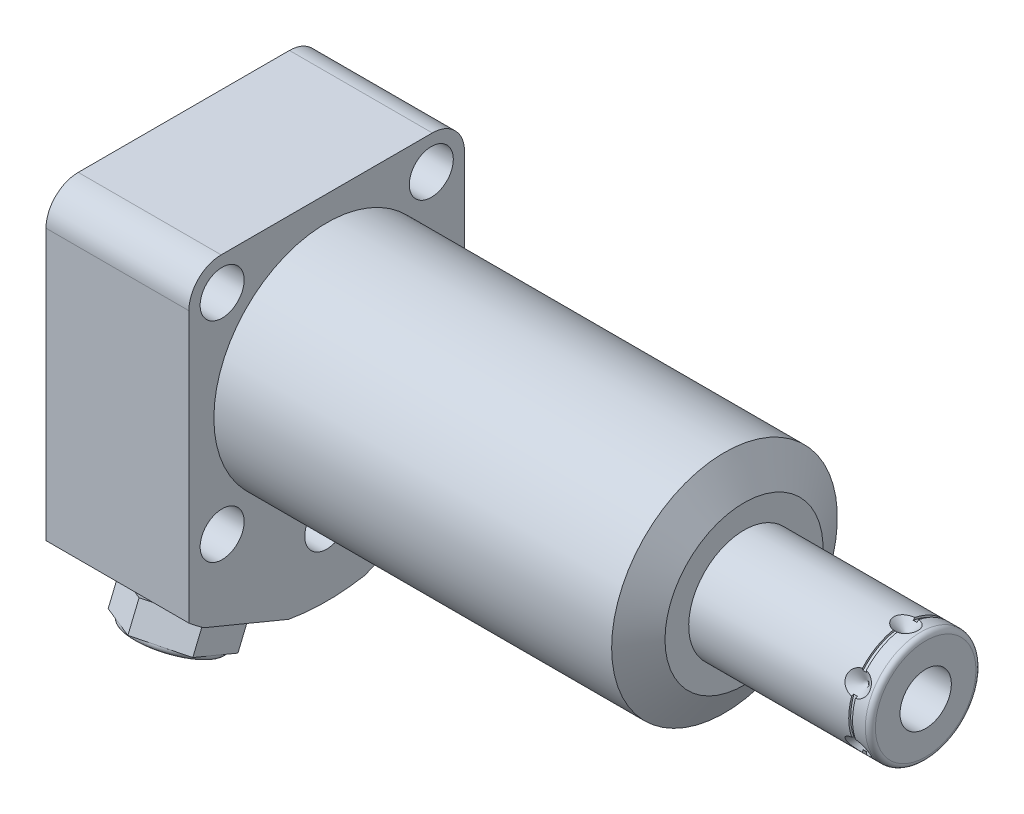
from build123d import *

# Parameters (mm, degrees)
EXTRUDE1_DEPTH           = 83.82
EXTRUDE1_DEPTH_BACK      = 28.702
CUT_EXTRUDE1_REACH       = 100.269
SKETCH2_R                = 22.6695
SKETCH11_W               = 0.762
SKETCH11_H               = 0.381
EXTRUDE2_DEPTH           = 7.87
SKETCH15_R               = 2.7432
EXTRUDE3_DEPTH           = 2.9972
CUT_EXTRUDE2_DEPTH       = 2.54
CHAMFER1_SIZE            = 0.381
CHAMFER1_OF_MIRROR2_SIZE = 0.381
SKETCH21_R               = 0.889
FILLET1_R                = 6.477
SKETCH22_W               = 4.4196
SKETCH22_H               = 28.702
HOLE1_AT_2_COUNT         = 2
HOLE1_AT_2_PITCH         = 54.877785999
HOLE1_AT_3_COUNT         = 2
HOLE1_AT_3_PITCH         = 54.877785999
HOLE1_AT_4_COUNT         = 2
HOLE1_AT_4_PITCH         = 22.73112685
HOLE1_AT_5_COUNT         = 2
HOLE1_AT_5_PITCH         = 22.73112685
CIRPATTERN1_COUNT        = 6


with BuildPart() as part:
    # Sketch1 → Extrude1 (new, two sides)
    with BuildSketch(Plane(origin=(0, 0, 0), x_dir=(0, 0, -1), z_dir=(1, 0, 0))) as extrude1_sk:
        with BuildLine():
            Line((-27.686, 27.686), (-27.686, -33.136049915))
            ThreePointArc((-27.686, -33.136049915), (-26.189365587, -34.331174319), (-24.641206283, -35.458755659))
            Line((-24.641206283, -35.458755659), (-7.649162519, -42.497090639))
            ThreePointArc((-7.649162519, -42.497090639), (0, -43.18), (7.649162519, -42.497090639))
            Line((7.649162519, -42.497090639), (24.641206283, -35.458755659))
            ThreePointArc((24.641206283, -35.458755659), (26.189365587, -34.331174319), (27.686, -33.136049915))
            Line((27.686, -33.136049915), (27.686, 27.686))
            Line((27.686, 27.686), (-27.686, 27.686))
        make_face()
    extrude(amount=EXTRUDE1_DEPTH)
    extrude(extrude1_sk.sketch, amount=-EXTRUDE1_DEPTH_BACK)

    # Sketch2 → Cut-Extrude1 (cut, up to next)
    with BuildSketch(Plane(origin=(0, 0, 0), x_dir=(0, 0, -1), z_dir=(1, 0, 0)), mode=Mode.PRIVATE) as cut_extrude1_sk1:
        with BuildLine():
            Line((27.686, 27.686), (-27.686, 27.686))
            Line((-27.686, 27.686), (-27.686, -33.136049915))
            ThreePointArc((-27.686, -33.136049915), (-26.189365587, -34.331174319), (-24.641206283, -35.458755659))
            Line((-24.641206283, -35.458755659), (-7.649162519, -42.497090639))
            ThreePointArc((-7.649162519, -42.497090639), (0, -43.18), (7.649162519, -42.497090639))
            Line((7.649162519, -42.497090639), (24.641206283, -35.458755659))
            ThreePointArc((24.641206283, -35.458755659), (26.189365587, -34.331174319), (27.686, -33.136049915))
            Line((27.686, -33.136049915), (27.686, 27.686))
        make_face()
        Circle(SKETCH2_R, mode=Mode.SUBTRACT)
    cut_extrude1_tool1 = extrude(cut_extrude1_sk1.sketch, amount=CUT_EXTRUDE1_REACH, mode=Mode.PRIVATE) & part.part
    add(cut_extrude1_tool1.solids().sort_by_distance((0, -33.616138, -25.643904))[0], mode=Mode.SUBTRACT)

    # Sketch3 → Cut-Revolve1 (revolve, cut)
    with BuildSketch(Plane.XY, mode=Mode.PRIVATE) as cut_revolve1_sk:
        Polygon((79.897193596, 22.6695), (83.82, 15.875), (83.82, 22.6695), align=None)
    revolve(cut_revolve1_sk.sketch.rotate(Axis((23.304450239, 0, 0), (1, 0, 0)), 90), axis=Axis((23.304450239, 0, 0), (1, 0, 0)), mode=Mode.SUBTRACT)

    # S2D0002 → Cut-Revolve2 (revolve, cut)
    with BuildSketch(Plane(origin=(-24.9936, -18.1864, 11.8618), x_dir=(0, 1, 0), z_dir=(0, 0, 1)), mode=Mode.PRIVATE) as cut_revolve2_sk:
        Polygon((-7.1374, 2.2606), (-4.6863, 2.2606), (-4.6863, 3.7084), (-10.3886, 3.7084), (-10.3886, -9.7282), (-9.144, -9.7282), (-9.144, -0.7366), (-7.1374, -0.7366), align=None)
    cut_revolve2 = revolve(cut_revolve2_sk.sketch.rotate(Axis((-1.435104963, -28.575, 11.8618), (-1, 0, 0)), 90), axis=Axis((-1.435104963, -28.575, 11.8618), (-1, 0, 0)), mode=Mode.SUBTRACT)

    # Sketch6 → Cut-Revolve4 (revolve, cut)
    with BuildSketch(Plane(origin=(-12.192, 0, 0), x_dir=(0, 0, -1), z_dir=(1, 0, 0)), mode=Mode.PRIVATE) as cut_revolve4_sk:
        Polygon((-22.196216323, -36.196576042), (-25.979687784, -34.62941085), (-26.076889376, -34.864076251), (-16.145184401, -38.977923149), (-10.624133986, -25.648928357), (-16.115304375, -23.374411109), (-21.218387946, -35.694344675), (-22.147615527, -36.079243341), align=None)
    cut_revolve4 = revolve(cut_revolve4_sk.sketch.rotate(Axis((-12.192, -11.999068119, 4.970176751), (0, 0.9238795325112866, -0.38268343236509017)), 180), axis=Axis((-12.192, -11.999068119, 4.970176751), (0, 0.9238795325112866, -0.38268343236509017)), mode=Mode.SUBTRACT)

    # Mirror1: Cut-Revolve2, Cut-Revolve4 across plane
    add(cut_revolve2.mirror(Plane.XY), mode=Mode.SUBTRACT)
    add(cut_revolve4.mirror(Plane.XY), mode=Mode.SUBTRACT)

    # Sketch7 → Revolve1 (revolve)
    with BuildSketch(Plane.XY, mode=Mode.PRIVATE) as revolve1_sk:
        with BuildLine():
            Line((83.82, 0), (83.82, 11.1125))
            Line((83.82, 11.1125), (119.291, 11.1125))
            ThreePointArc((119.291, 11.1125), (120.00942049, 10.81492049), (120.307, 10.0965))
            Line((120.307, 10.0965), (120.307, 0))
            Line((120.307, 0), (83.82, 0))
        make_face()
    revolve(revolve1_sk.sketch.rotate(Axis((4.993122661, 0, 0), (1, 0, 0)), 180), axis=Axis((4.993122661, 0, 0), (1, 0, 0)))

    # S2D0001 → Cut-Revolve8 (revolve, cut)
    with BuildSketch(Plane.XY, mode=Mode.PRIVATE) as cut_revolve8_sk:
        Polygon((120.307, -5.1562), (103.289, -5.1562), (100.190842476, 0), (120.307, 0), align=None)
    revolve(cut_revolve8_sk.sketch.rotate(Axis((-2.5273, 0, 0), (-1, 0, 0)), 180), axis=Axis((-2.5273, 0, 0), (-1, 0, 0)), mode=Mode.SUBTRACT)

    # Sketch9 → Cut-Revolve9 (revolve, cut)
    with BuildSketch(Plane.XY, mode=Mode.PRIVATE) as cut_revolve9_sk:
        Polygon((116.3446, -11.1125), (113.9316, -11.1125), (116.3446, -8.6995), align=None)
    cut_revolve9 = revolve(cut_revolve9_sk.sketch.rotate(Axis((116.3446, -6.253416753, 0), (0, 1, 0)), 270), axis=Axis((116.3446, -6.253416753, 0), (0, 1, 0)), mode=Mode.SUBTRACT)

    # Sketch11 → Cut-Revolve5 (revolve, cut)
    with BuildSketch(Plane(origin=(0, 0, 0), x_dir=(1, 0, 0), z_dir=(0, 1, 0)), mode=Mode.PRIVATE) as cut_revolve5_sk:
        with Locations((116.3446, -10.922)):
            Rectangle(SKETCH11_W, SKETCH11_H)
    revolve(cut_revolve5_sk.sketch.rotate(Axis((0, 0, 0), (1, 0, 0)), 90), axis=Axis((0, 0, 0), (1, 0, 0)), mode=Mode.SUBTRACT)

    # Sketch12 → Extrude2 (add)
    with BuildSketch(Plane(origin=(0, -38.743257748, 16.04798281), x_dir=(1, 0, 0), z_dir=(0, -0.9238795325112866, 0.38268343236509017))):
        Polygon((-12.192, -9.814954576), (-3.692, -4.907477288), (-3.692, 4.907477288), (-12.192, 9.814954576), (-20.692, 4.907477288), (-20.692, -4.907477288), align=None)
    extrude(amount=EXTRUDE2_DEPTH)

    # Sketch13 → Cut-Revolve6 (revolve, cut)
    with BuildSketch(Plane(origin=(-12.192, -6.4643, -11.196496035), x_dir=(0, -0.8660254037844385, 0.5000000000000003), z_dir=(1, 0, 0)), mode=Mode.PRIVATE) as cut_revolve6_sk:
        Polygon((40.467164206, 0.972349403), (41.458609067, 1.102875595), (41.164925135, 3.333626533), (40.173480273, 3.203100341), align=None)
        with BuildLine():
            Line((47.278390403, 1.869064343), (46.984706471, 4.099815282))
            Line((46.984706471, 4.099815282), (47.976151332, 4.230341474))
            Line((47.976151332, 4.230341474), (48.400361457, 1.008145674))
            ThreePointArc((48.400361457, 1.008145674), (48.017678025, 1.670972822), (47.278390403, 1.869064343))
        make_face()
    revolve(cut_revolve6_sk.sketch.rotate(Axis((-12.192, -27.554378452, 11.413397257), (0, -0.9238795325112866, 0.38268343236509034)), 180), axis=Axis((-12.192, -27.554378452, 11.413397257), (0, -0.9238795325112866, 0.38268343236509034)), mode=Mode.SUBTRACT)

    # Sketch15 → Extrude3 (add)
    with BuildSketch(Plane.ZY.offset(24.257)):
        with Locations(Location((11.8618, -28.575, 0), (0, 0, 180))):
            Circle(SKETCH15_R)
    extrude3 = extrude(amount=EXTRUDE3_DEPTH)

    # Sketch16 → Cut-Extrude2 (cut)
    with BuildSketch(Plane.ZY.offset(27.2542)):
        Polygon((13.29894029, -28.575), (12.580370145, -27.3304), (11.143229855, -27.3304), (10.42465971, -28.575), (11.143229855, -29.8196), (12.580370145, -29.8196), align=None)
    cut_extrude2 = extrude(amount=-CUT_EXTRUDE2_DEPTH, mode=Mode.SUBTRACT)

    # Chamfer1
    chamfer1_edges = [part.edges().sort_by_distance(p)[0] for p in [
        (-27.2542, -28.575, 14.605),
    ]]
    chamfer(chamfer1_edges, length=CHAMFER1_SIZE)

    # Mirror2: Extrude3, Cut-Extrude2 across plane
    add(extrude3.mirror(Plane.XY))
    add(cut_extrude2.mirror(Plane.XY), mode=Mode.SUBTRACT)

    # Chamfer1 of Mirror2
    chamfer1_of_mirror2_edges = [part.edges().sort_by_distance(p)[0] for p in [
        (-27.2542, -28.575, -14.605),
    ]]
    chamfer(chamfer1_of_mirror2_edges, length=CHAMFER1_OF_MIRROR2_SIZE)

    # Fillet1
    fillet1_edges = [part.edges().sort_by_distance(p)[0] for p in [
        (-14.351, 27.686, -27.686),
        (-14.351, 27.686, 27.686),
    ]]
    fillet(fillet1_edges, radius=FILLET1_R)

    # Sketch22 → Hole1 (revolve, cut)
    with BuildSketch(Plane(origin=(0, -29.6926, 0), x_dir=(0, 0, -1), z_dir=(0, 1, 0))):
        with Locations((2.2098, 14.351)):
            Rectangle(SKETCH22_W, SKETCH22_H)
    hole1 = revolve(axis=Axis((-110, -29.6926, 0), (1, 0, 0)), mode=Mode.SUBTRACT)

    # Hole1 at 2: Hole1 ×2
    with Locations(*[Vector(0, 0.9238419348863701, 0.3827741884524189) * (i * HOLE1_AT_2_PITCH) for i in range(1, HOLE1_AT_2_COUNT)]):
        add(hole1, mode=Mode.SUBTRACT)

    # Hole1 at 3: Hole1 ×2
    with Locations(*[Vector(0, 0.9238419348863701, -0.3827741884524189) * (i * HOLE1_AT_3_PITCH) for i in range(1, HOLE1_AT_3_COUNT)]):
        add(hole1, mode=Mode.SUBTRACT)

    # Hole1 at 4: Hole1 ×2
    with Locations(*[Vector(0, 0.3821543937194909, 0.9240984900760786) * (i * HOLE1_AT_4_PITCH) for i in range(1, HOLE1_AT_4_COUNT)]):
        add(hole1, mode=Mode.SUBTRACT)

    # Hole1 at 5: Hole1 ×2
    with Locations(*[Vector(0, 0.38215439371949145, -0.9240984900760785) * (i * HOLE1_AT_5_PITCH) for i in range(1, HOLE1_AT_5_COUNT)]):
        add(hole1, mode=Mode.SUBTRACT)

    # CirPattern1: Cut-Revolve9 ×6 about axis
    cirpattern1_axis = Axis((83.821, 0, 0), (-1, 0, 0))
    for i in range(1, CIRPATTERN1_COUNT):
        add(cut_revolve9.rotate(cirpattern1_axis, i * 360 / CIRPATTERN1_COUNT), mode=Mode.SUBTRACT)


with BuildPart() as body_2:
    # Sketch21 → Revolve4 (revolve)
    with BuildSketch(Plane.XY.offset(11.8618), mode=Mode.PRIVATE) as revolve4_sk:
        with Locations((-28.1178, -23.7617)):
            Circle(SKETCH21_R)
    revolve(revolve4_sk.sketch.rotate(Axis((-35.974373203, -28.575, 11.8618), (1, 0, 0)), 90), axis=Axis((-35.974373203, -28.575, 11.8618), (1, 0, 0)))


with BuildPart() as body_3:
    # Mirror3: mirrored copy
    add(body_2.part.mirror(Plane.XY))


solid = Compound([part.part, body_2.part, body_3.part])
